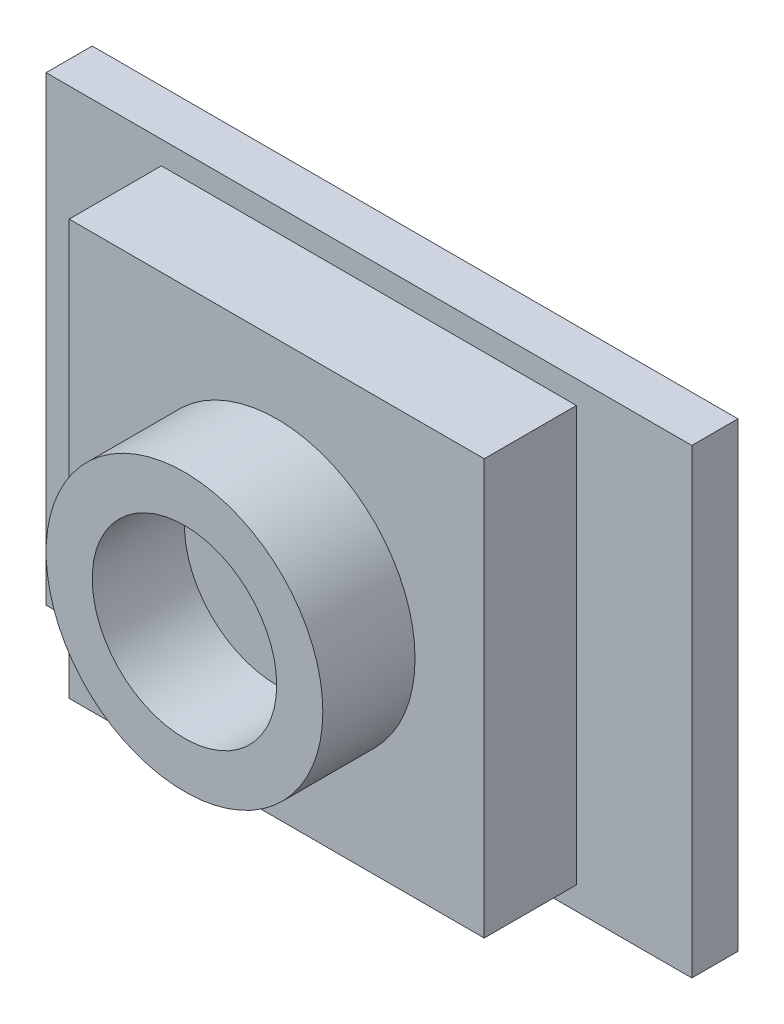
from build123d import *

# Parameters (mm, degrees)
SKETCH2_W           = 88.9
SKETCH2_H           = 63.5
BOSS_EXTRUDE1_DEPTH = 6.35
SKETCH3_W           = 57.15
SKETCH3_H           = 57.15
BOSS_EXTRUDE2_DEPTH = 12.7
SKETCH4_R           = 19.05
SKETCH4_R_2         = 12.7
BOSS_EXTRUDE3_DEPTH = 12.7


with BuildPart() as part:
    # Sketch2 → Boss-Extrude1 (new body)
    with BuildSketch(Plane.XY):
        Rectangle(SKETCH2_W, SKETCH2_H)
    extrude(amount=-BOSS_EXTRUDE1_DEPTH)

    # Sketch3 → Boss-Extrude2 (add)
    with BuildSketch(Plane.XY):
        Rectangle(SKETCH3_W, SKETCH3_H)
    extrude(amount=BOSS_EXTRUDE2_DEPTH)

    # Sketch4 → Boss-Extrude3 (add)
    with BuildSketch(Plane.XY.offset(12.7)):
        Circle(SKETCH4_R)
        Circle(SKETCH4_R_2, mode=Mode.SUBTRACT)
    extrude(amount=BOSS_EXTRUDE3_DEPTH)


solid = part.part
